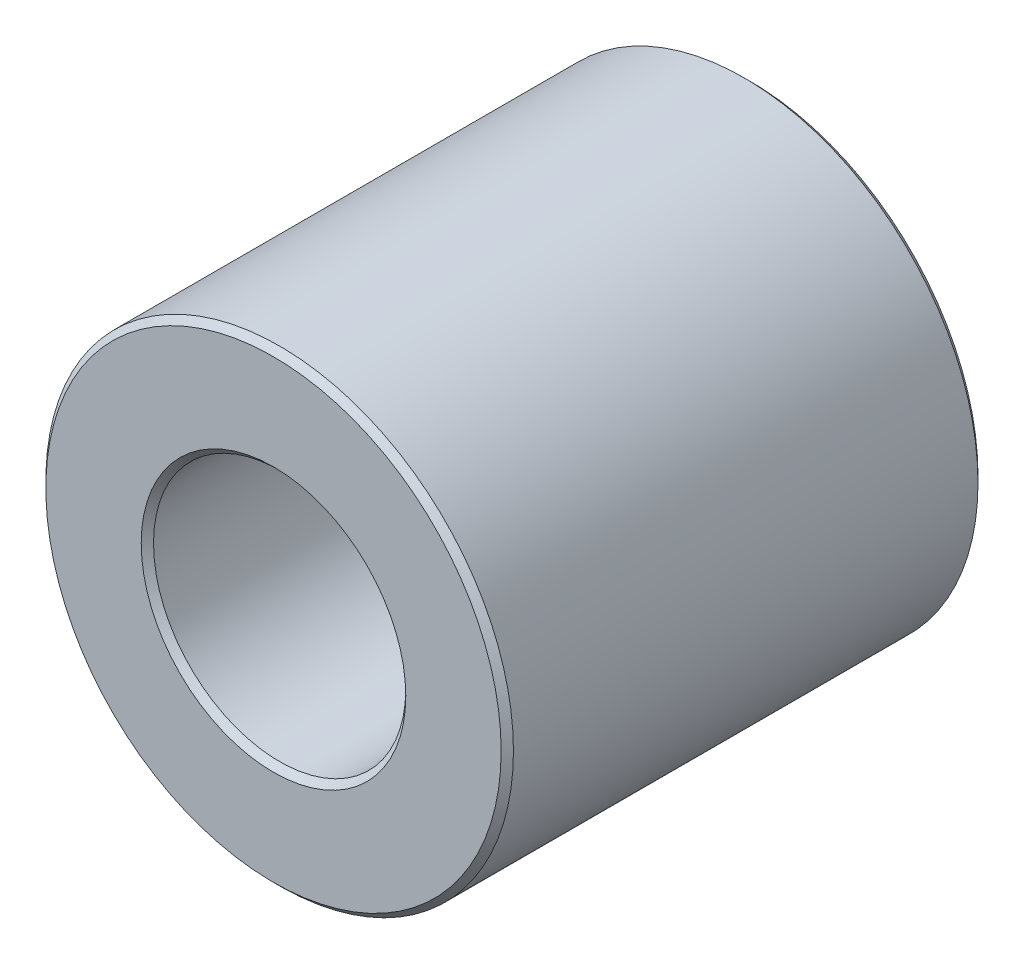
from build123d import *

# Parameters (mm, degrees)
ESQUISSE1_R        = 7.6
ESQUISSE1_R_2      = 4.1
BOSS_EXTRU_1_DEPTH = 15.5
CHANFREIN1_SIZE    = 0.2


with BuildPart() as part:
    # Esquisse1 → Boss.-Extru.1 (new body)
    with BuildSketch(Plane.XY):
        Circle(ESQUISSE1_R)
        Circle(ESQUISSE1_R_2, mode=Mode.SUBTRACT)
    extrude(amount=BOSS_EXTRU_1_DEPTH)

    # Chanfrein1
    chanfrein1_edges = [part.edges().sort_by_distance(p)[0] for p in [
        (-7.6, 0, 0),
        (-7.6, 0, 15.5),
        (-4.1, 0, 0),
        (-4.1, 0, 15.5),
    ]]
    chamfer(chanfrein1_edges, length=CHANFREIN1_SIZE)


solid = part.part
